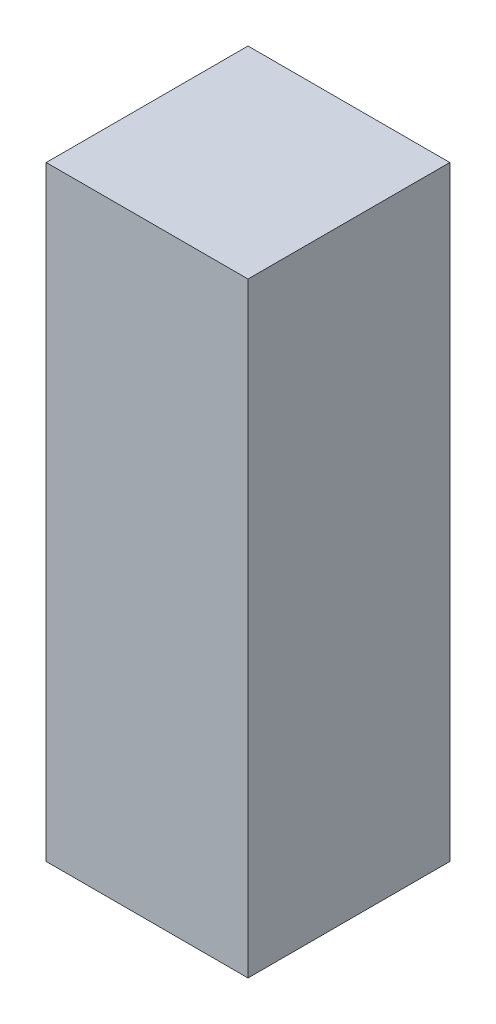
from build123d import *

# Parameters (mm, degrees)
MODEL_W             = 6
MODEL_H             = 18
BOSS_EXTRUDE1_DEPTH = 6


with BuildPart() as part:
    # Model → Boss-Extrude1 (new body)
    with BuildSketch(Plane.XY):
        with Locations((33.933244503, 16.044780119)):
            Rectangle(MODEL_W, MODEL_H)
    extrude(amount=BOSS_EXTRUDE1_DEPTH)


solid = part.part
